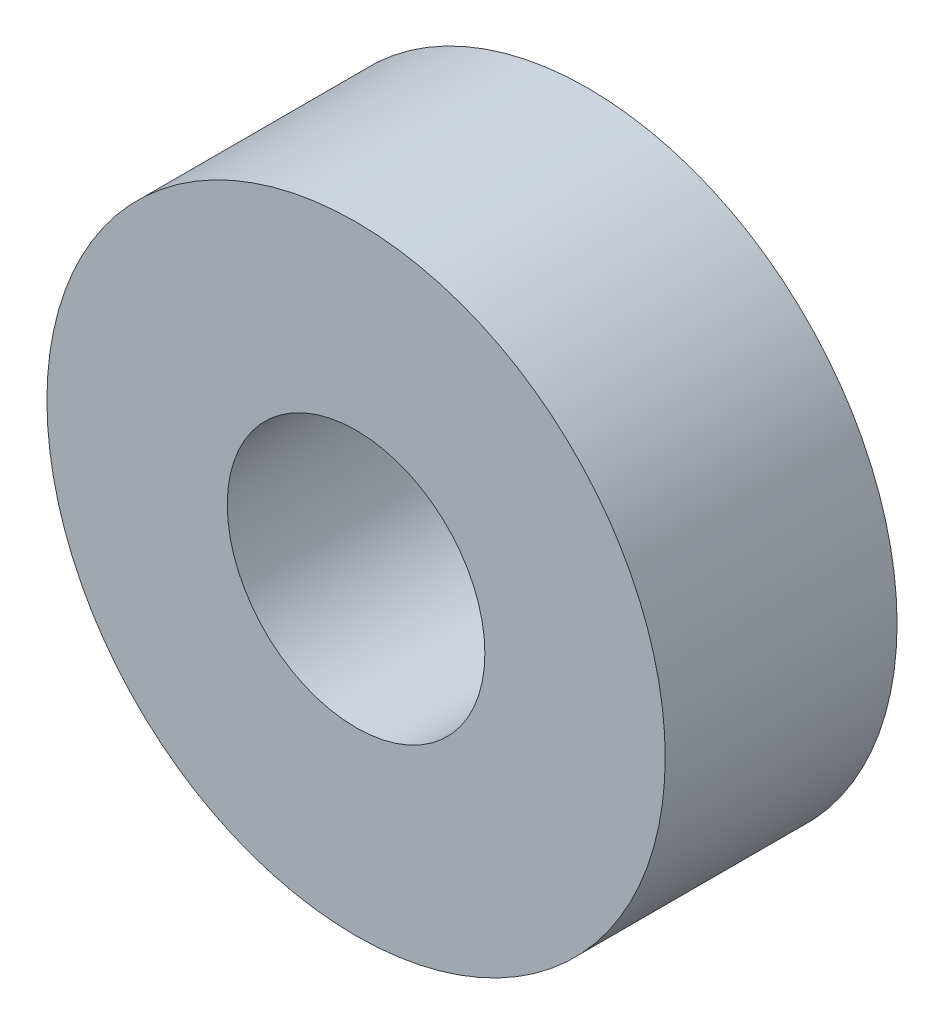
from build123d import *

# Parameters (mm, degrees)
SKETCH_1_R      = 6
SKETCH_1_R_2    = 2.5
EXTRUDE_1_DEPTH = 4.5


with BuildPart() as part:
    # 草图1 → 凸台-拉伸1 (new body)
    with BuildSketch(Plane.XY):
        Circle(SKETCH_1_R)
        Circle(SKETCH_1_R_2, mode=Mode.SUBTRACT)
    extrude(amount=EXTRUDE_1_DEPTH)


solid = part.part
